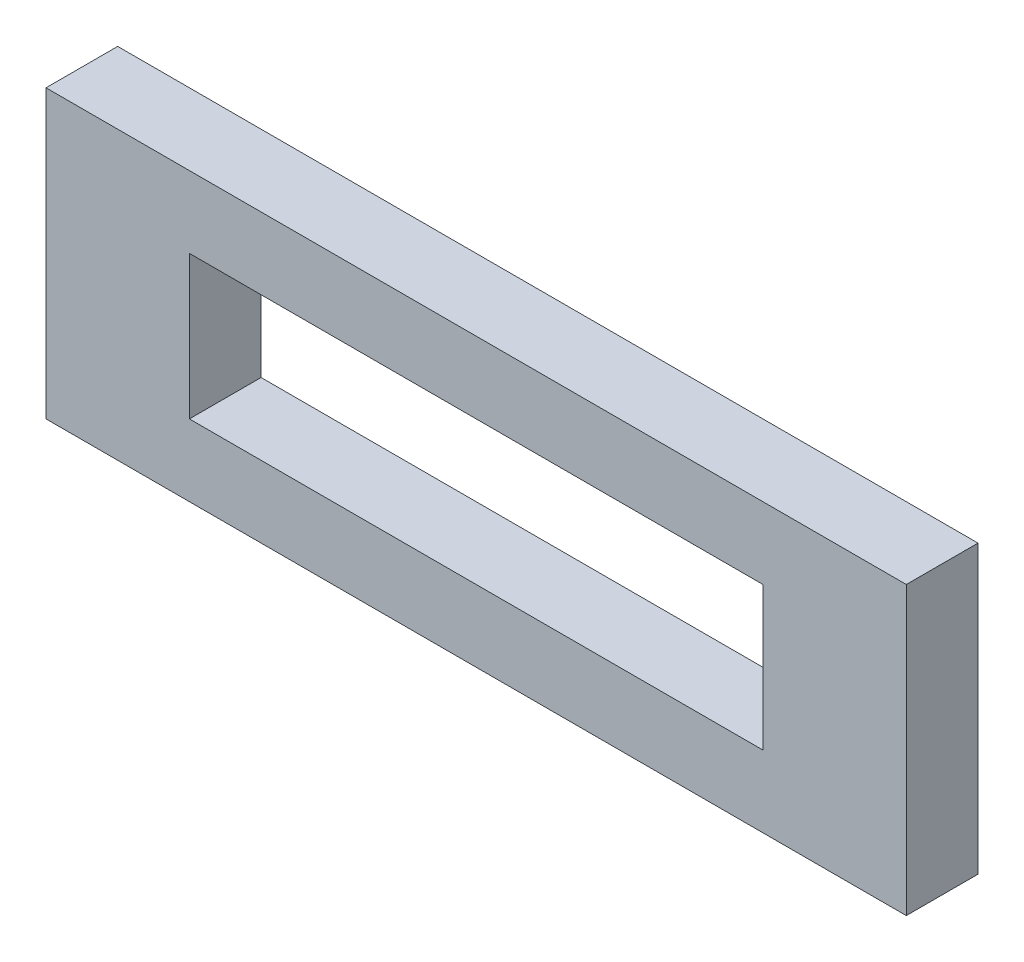
from build123d import *

# Parameters (mm, degrees)
SKETCH1_W      = 38.1
SKETCH1_H      = 12.7
SKETCH1_W_2    = 25.4
SKETCH1_H_2    = 6.35
EXTRUDE1_DEPTH = 3.175


with BuildPart() as part:
    # Sketch1 → Extrude1 (new body)
    with BuildSketch(Plane.XY):
        Rectangle(SKETCH1_W, SKETCH1_H)
        Rectangle(SKETCH1_W_2, SKETCH1_H_2, mode=Mode.SUBTRACT)
    extrude(amount=EXTRUDE1_DEPTH)


solid = part.part
